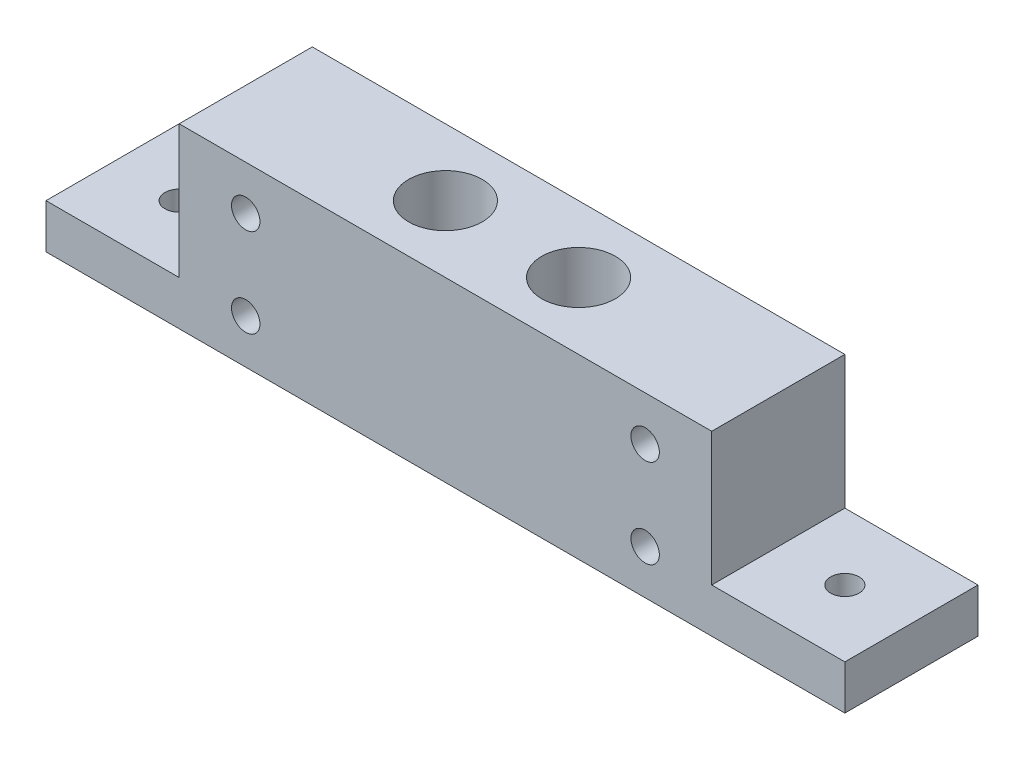
from build123d import *

# Parameters (mm, degrees)
SKETCH2_W           = 60
SKETCH2_H           = 15
SKETCH2_R           = 4.15
BOSS_EXTRUDE1_DEPTH = 10
SKETCH2_3_W         = 60
SKETCH2_3_H         = 15
BOSS_EXTRUDE2_DEPTH = 10
SKETCH4_R           = 1.6
CUT_EXTRUDE1_DEPTH  = 36
CUT_EXTRUDE2_START  = -6.25
SKETCH4_3_R         = 1.6
CUT_EXTRUDE2_DEPTH  = 2.5
SKETCH5_W           = 15
SKETCH5_H           = 15
BOSS_EXTRUDE3_DEPTH = 5
CUT_EXTRUDE3_REACH  = 51.812
SKETCH6_R           = 1.6
CUT_EXTRUDE4_START  = -8
SKETCH7_R           = 4.15
CUT_EXTRUDE4_DEPTH  = 8


with BuildPart() as part:
    # Sketch2 → Boss-Extrude1 (new body)
    with BuildSketch(Plane(origin=(0, 0, 0), x_dir=(1, 0, 0), z_dir=(0, 1, 0))):
        Rectangle(SKETCH2_W, SKETCH2_H)
        with Locations((-7.5, 0)):
            Circle(SKETCH2_R, mode=Mode.SUBTRACT)
        with Locations((7.5, 0)):
            Circle(SKETCH2_R, mode=Mode.SUBTRACT)
    extrude(amount=BOSS_EXTRUDE1_DEPTH)

    # Sketch2_3 → Boss-Extrude2 (add)
    with BuildSketch(Plane(origin=(0, 0, 0), x_dir=(1, 0, 0), z_dir=(0, 1, 0))):
        Rectangle(SKETCH2_3_W, SKETCH2_3_H)
    extrude(amount=-BOSS_EXTRUDE2_DEPTH)

    # Sketch4 → Cut-Extrude1 (cut, through all)
    with BuildSketch(Plane.XY.offset(7.5)):
        with Locations((22.5, 5)):
            Circle(SKETCH4_R)
        with Locations((22.5, -5)):
            Circle(SKETCH4_R)
        with Locations((-22.5, -5)):
            Circle(SKETCH4_R)
        with Locations((-22.5, 5)):
            Circle(SKETCH4_R)
    extrude(amount=-CUT_EXTRUDE1_DEPTH, mode=Mode.SUBTRACT)

    # Sketch4_3 → Cut-Extrude2 (cut)
    # profile 1 of 4: a face of its own
    with BuildSketch(Plane.XY.offset(7.5).offset(CUT_EXTRUDE2_START)):
        Polygon((-22.5, 8.435234102), (-25.475, 6.717617051), (-25.475, 3.282382949), (-22.5, 1.564765898), (-19.525, 3.282382949), (-19.525, 6.717617051), align=None)
        with Locations((-22.5, 5)):
            Circle(SKETCH4_3_R, mode=Mode.SUBTRACT)
    # profile 2 of 4: a face of its own
    with BuildSketch(Plane.XY.offset(7.5).offset(CUT_EXTRUDE2_START)):
        Polygon((22.5, 8.435234102), (19.525, 6.717617051), (19.525, 3.282382949), (22.5, 1.564765898), (25.475, 3.282382949), (25.475, 6.717617051), align=None)
        with Locations((22.5, 5)):
            Circle(SKETCH4_3_R, mode=Mode.SUBTRACT)
    # profile 3 of 4: a face of its own
    with BuildSketch(Plane.XY.offset(7.5).offset(CUT_EXTRUDE2_START)):
        Polygon((-22.5, -8.435234102), (-19.525, -6.717617051), (-19.525, -3.282382949), (-22.5, -1.564765898), (-25.475, -3.282382949), (-25.475, -6.717617051), align=None)
        with Locations((-22.5, -5)):
            Circle(SKETCH4_3_R, mode=Mode.SUBTRACT)
    # profile 4 of 4: a face of its own
    with BuildSketch(Plane.XY.offset(7.5).offset(CUT_EXTRUDE2_START)):
        Polygon((22.5, -8.435234102), (25.475, -6.717617051), (25.475, -3.282382949), (22.5, -1.564765898), (19.525, -3.282382949), (19.525, -6.717617051), align=None)
        with Locations((22.5, -5)):
            Circle(SKETCH4_3_R, mode=Mode.SUBTRACT)
    extrude(amount=-CUT_EXTRUDE2_DEPTH, mode=Mode.SUBTRACT)

    # Sketch5 → Boss-Extrude3 (add)
    with BuildSketch(Plane.XZ.offset(10)):
        with Locations((-37.5, 0)):
            Rectangle(SKETCH5_W, SKETCH5_H)
        with Locations((37.5, 0)):
            Rectangle(SKETCH5_W, SKETCH5_H)
    extrude(amount=-BOSS_EXTRUDE3_DEPTH)

    # Sketch6 → Cut-Extrude3 (cut, up to next)
    with BuildSketch(Plane.XZ.offset(10), mode=Mode.PRIVATE) as cut_extrude3_sk1:
        with Locations((-37.5, 0)):
            Circle(SKETCH6_R)
    cut_extrude3_tool1 = extrude(cut_extrude3_sk1.sketch, amount=-CUT_EXTRUDE3_REACH, mode=Mode.PRIVATE) & part.part
    # Sketch6 → Cut-Extrude3 (cut, up to next)
    with BuildSketch(Plane.XZ.offset(10), mode=Mode.PRIVATE) as cut_extrude3_sk2:
        with Locations((37.5, 0)):
            Circle(SKETCH6_R)
    cut_extrude3_tool2 = extrude(cut_extrude3_sk2.sketch, amount=-CUT_EXTRUDE3_REACH, mode=Mode.PRIVATE) & part.part
    add(cut_extrude3_tool1.solids().sort_by_distance((-37.5, -10, 0))[0], mode=Mode.SUBTRACT)
    add(cut_extrude3_tool2.solids().sort_by_distance((37.5, -10, 0))[0], mode=Mode.SUBTRACT)

    # Sketch7 → Cut-Extrude4 (cut)
    with BuildSketch(Plane(origin=(0, 0, 0), x_dir=(1, 0, 0), z_dir=(0, 1, 0)).offset(CUT_EXTRUDE4_START)):
        with Locations((-7.5, 0)):
            Circle(SKETCH7_R)
        with Locations((7.5, 0)):
            Circle(SKETCH7_R)
    extrude(amount=CUT_EXTRUDE4_DEPTH, mode=Mode.SUBTRACT)


solid = part.part
